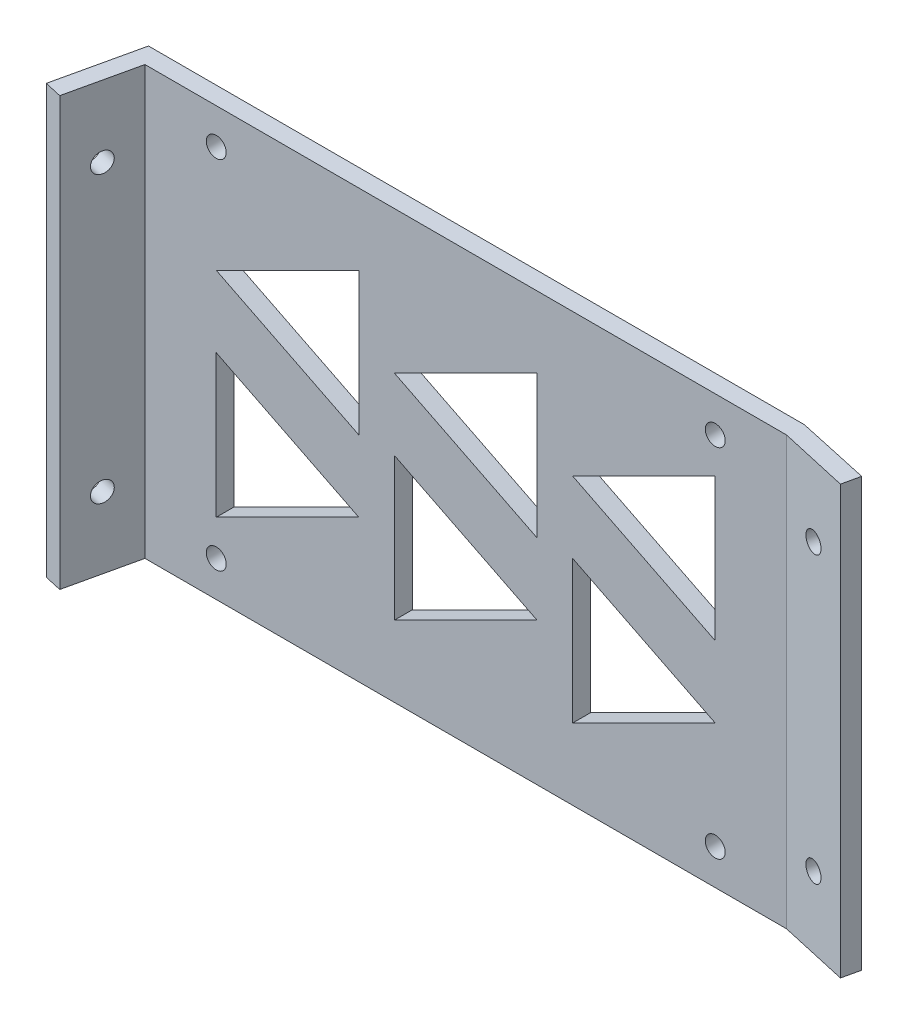
from build123d import *

# Parameters (mm, degrees)
SKETCH1_W           = 114.3
SKETCH1_H           = 76.2
BOSS_EXTRUDE1_DEPTH = 3.175
BOSS_EXTRUDE2_DEPTH = 76.2
SKETCH3_R           = 1.778
CUT_EXTRUDE1_DEPTH  = 203.2
CUT_EXTRUDE2_DEPTH  = 3.175
LPATTERN1_COUNT     = 3
LPATTERN1_PITCH     = 31.75
SKETCH5_R           = 1.778
CUT_EXTRUDE3_DEPTH  = 3.175
SKETCH6_R           = 1.778
CUT_EXTRUDE4_DEPTH  = 3.175


with BuildPart() as part:
    # Sketch1 → Boss-Extrude1 (new body)
    with BuildSketch(Plane.XY):
        with Locations((-57.15, -38.1)):
            Rectangle(SKETCH1_W, SKETCH1_H)
    extrude(amount=BOSS_EXTRUDE1_DEPTH)

    # Sketch2 → Boss-Extrude2 (add)
    with BuildSketch(Plane.XZ.offset(76.2)):
        Polygon((-114.3, 3.175), (-117.087804878, 15.565243902), (-120.185365854, 14.868292683), (-116.84, 0), (-114.3, 0), align=None)
        Polygon((0, 3.175), (0, 0), (13.087195122, 2.865243902), (12.390243902, 5.962804878), align=None)
    extrude(amount=-BOSS_EXTRUDE2_DEPTH)

    # Sketch3 → Cut-Extrude1 (cut)
    with BuildSketch(Plane(origin=(-108.112433076, 0, -24.325297442), x_dir=(0.219512195, 0, -0.975609756), z_dir=(0.975609756, 0, 0.219512195))):
        with Locations((-34.537804878, -12.7)):
            Circle(SKETCH3_R)
        with Locations((-34.537804878, -63.5)):
            Circle(SKETCH3_R)
    extrude(amount=-CUT_EXTRUDE1_DEPTH, mode=Mode.SUBTRACT)

    # Sketch4 → Cut-Extrude2 (cut)
    with BuildSketch(Plane.XY.offset(3.175)):
        Polygon((-101.6, -63.5), (-101.6, -38.1), (-76.2, -50.8), align=None)
        Polygon((-101.6, -25.4), (-76.2, -38.1), (-76.2, -12.7), align=None)
    cut_extrude2 = extrude(amount=-CUT_EXTRUDE2_DEPTH, mode=Mode.SUBTRACT)

    # LPattern1: Cut-Extrude2 ×3
    with Locations(*[(i * LPATTERN1_PITCH, 0, 0) for i in range(1, LPATTERN1_COUNT)]):
        add(cut_extrude2, mode=Mode.SUBTRACT)

    # Sketch5 → Cut-Extrude3 (cut)
    with BuildSketch(Plane.XY.offset(3.175)):
        with Locations((-101.6, -69.85)):
            Circle(SKETCH5_R)
        with Locations((-12.7, -69.85)):
            Circle(SKETCH5_R)
        with Locations((-12.7, -6.35)):
            Circle(SKETCH5_R)
        with Locations((-101.6, -6.35)):
            Circle(SKETCH5_R)
    extrude(amount=-CUT_EXTRUDE3_DEPTH, mode=Mode.SUBTRACT)

    # Sketch6 → Cut-Extrude4 (cut)
    with BuildSketch(Plane(origin=(-0.679952409, 0, 3.022010708), x_dir=(0.975609756, 0, 0.219512195), z_dir=(-0.219512195, 0, 0.975609756))):
        with Locations((7.04695122, -63.5)):
            Circle(SKETCH6_R)
        with Locations((7.04695122, -12.7)):
            Circle(SKETCH6_R)
    extrude(amount=-CUT_EXTRUDE4_DEPTH, mode=Mode.SUBTRACT)


solid = part.part
